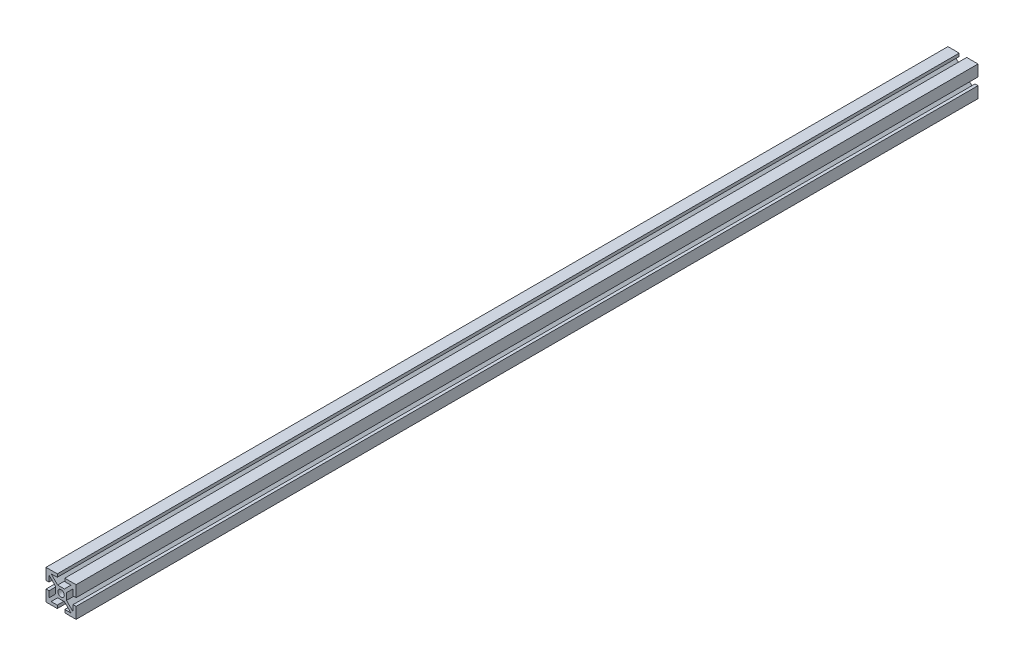
from build123d import *

# Parameters (mm, degrees)
ESQUISSE1_R        = 2.15
BOSS_EXTRU_1_DEPTH = 600


with BuildPart() as part:
    # Esquisse1 → Boss.-Extru.1 (new body)
    with BuildSketch(Plane.XY):
        Polygon((-2.5, 10), (-10, 10), (-10, 2.5), (-8, 2.5), (-8, 6.585786438), (-3.65, 2.235786438), (-3.65, -2.235786438), (-8, -6.585786438), (-8, -2.5), (-10, -2.5), (-10, -10), (-2.5, -10), (-2.5, -8), (-6.585786438, -8), (-2.235786438, -3.65), (2.235786438, -3.65), (6.585786438, -8), (2.5, -8), (2.5, -10), (10, -10), (10, -2.5), (8, -2.5), (8, -6.585786438), (3.65, -2.235786438), (3.65, 2.235786438), (8, 6.585786438), (8, 2.5), (10, 2.5), (10, 10), (2.5, 10), (2.5, 8), (6.585786438, 8), (2.235786438, 3.65), (-2.235786438, 3.65), (-6.585786438, 8), (-2.5, 8), align=None)
        Circle(ESQUISSE1_R, mode=Mode.SUBTRACT)
    extrude(amount=BOSS_EXTRU_1_DEPTH)


solid = part.part
